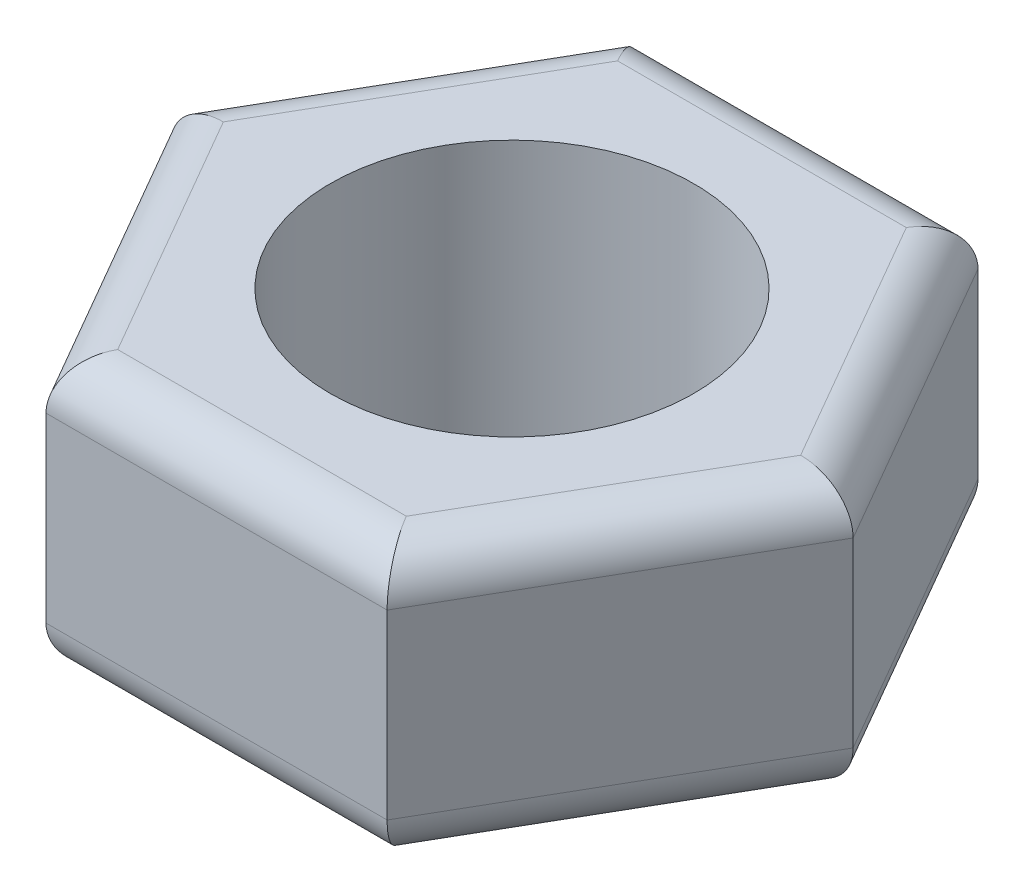
from build123d import *

# Parameters (mm, degrees)
SKETCH1_R           = 4
BOSS_EXTRUDE1_DEPTH = 6
FILLET1_R           = 1


with BuildPart() as part:
    # Sketch1 → Boss-Extrude1 (new body)
    with BuildSketch(Plane(origin=(0, 0, 0), x_dir=(1, 0, 0), z_dir=(0, 1, 0))):
        Polygon((7.505553499, 0), (3.75277675, 6.5), (-3.75277675, 6.5), (-7.505553499, 0), (-3.75277675, -6.5), (3.75277675, -6.5), align=None)
        Circle(SKETCH1_R, mode=Mode.SUBTRACT)
    extrude(amount=BOSS_EXTRUDE1_DEPTH)

    # Fillet1
    fillet1_edges = [part.edges().sort_by_distance(p)[0] for p in [
        (0, 6, -6.5),
        (-5.629165125, 6, -3.25),
        (-5.629165125, 6, 3.25),
        (0, 6, 6.5),
        (5.629165125, 6, 3.25),
        (0, 0, 6.5),
        (-5.629165125, 0, 3.25),
        (-5.629165125, 0, -3.25),
        (0, 0, -6.5),
        (5.629165125, 0, -3.25),
        (5.629165125, 0, 3.25),
        (5.629165125, 6, -3.25),
    ]]
    fillet(fillet1_edges, radius=FILLET1_R)


solid = part.part
